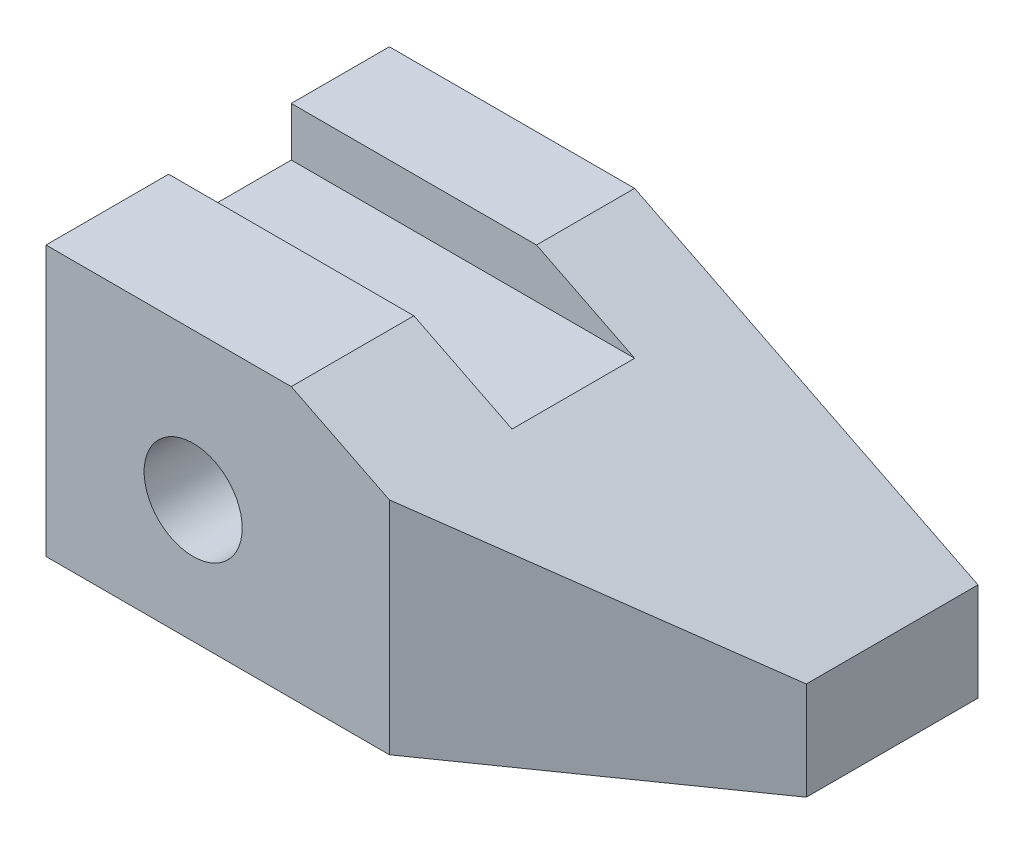
from build123d import *

# Parameters (mm, degrees)
BOSS_EXTRUDE1_DEPTH      = 44.45
SKETCH2_W                = 88.9
SKETCH2_H                = 31.75
CUT_EXTRUDE1_DEPTH       = 12.7
CUT_EXTRUDE2_DEPTH       = 174.437553604
F_1_4_1_DIAMETER_HOLE1_D = 25.4


with BuildPart() as part:
    # Sketch1 → Boss-Extrude1 (new, symmetric)
    with BuildSketch(Plane.XY):
        Polygon((0, 0), (0, 69.85), (63.5, 69.85), (88.9, 57.15), (152.4, 25.4), (152.4, 0), align=None)
    extrude(amount=BOSS_EXTRUDE1_DEPTH, both=True)

    # Sketch2 → Cut-Extrude1 (cut)
    with BuildSketch(Plane(origin=(0, 69.85, 0), x_dir=(1, 0, 0), z_dir=(0, 1, 0))):
        with Locations((44.45, 3.175)):
            Rectangle(SKETCH2_W, SKETCH2_H)
    extrude(amount=-CUT_EXTRUDE1_DEPTH, mode=Mode.SUBTRACT)

    # Sketch3 → Cut-Extrude2 (cut, through all)
    with BuildSketch(Plane(origin=(0, 0, 0), x_dir=(1, 0, 0), z_dir=(0, 1, 0))):
        Polygon((88.9, -44.45), (152.4, 0), (152.4, -44.45), align=None)
    extrude(amount=CUT_EXTRUDE2_DEPTH, mode=Mode.SUBTRACT)

    # 1_4 _1_ Diameter Hole1 (through all)
    with Locations(Plane.XY.offset(44.45)):
        with Locations((38.1, 31.75)):
            Hole(F_1_4_1_DIAMETER_HOLE1_D / 2)


solid = part.part
